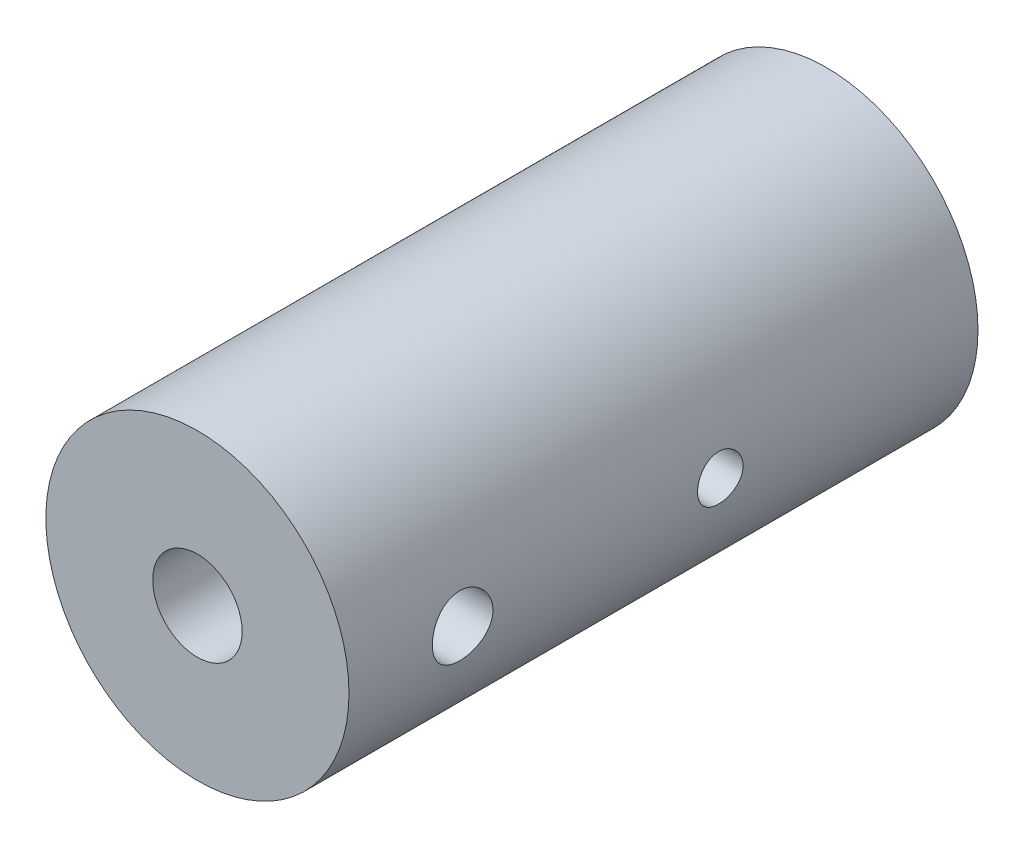
from build123d import *

# Parameters (mm, degrees)
SKETCH1_R           = 10
BOSS_EXTRUDE1_DEPTH = 41.5
SKETCH2_R           = 2.95
CUT_EXTRUDE1_DEPTH  = 15
SKETCH3_R           = 6
CUT_EXTRUDE2_DEPTH  = 22
CUT_EXTRUDE3_REACH  = 49.141
SKETCH4_R           = 1.5
SKETCH4_R_2         = 2
CUT_EXTRUDE4_REACH  = 69.141
CUT_EXTRUDE4_START  = -20
SKETCH4_2_R         = 1.5
SKETCH4_2_R_2       = 2


with BuildPart() as part:
    # Sketch1 → Boss-Extrude1 (new body)
    with BuildSketch(Plane.XY):
        Circle(SKETCH1_R)
    extrude(amount=BOSS_EXTRUDE1_DEPTH)

    # Sketch2 → Cut-Extrude1 (cut)
    with BuildSketch(Plane.XY.offset(41.5)):
        Circle(SKETCH2_R)
    extrude(amount=-CUT_EXTRUDE1_DEPTH, mode=Mode.SUBTRACT)

    # Sketch3 → Cut-Extrude2 (cut)
    with BuildSketch(Plane(origin=(0, 0, 0), x_dir=(-1, 0, 0), z_dir=(0, 0, -1))):
        Circle(SKETCH3_R)
    extrude(amount=-CUT_EXTRUDE2_DEPTH, mode=Mode.SUBTRACT)

    # Sketch4 → Cut-Extrude3 (cut, up to next)
    with BuildSketch(Plane.ZY.offset(10), mode=Mode.PRIVATE) as cut_extrude3_sk1:
        with Locations((17, 0)):
            Circle(SKETCH4_R)
    cut_extrude3_tool1 = extrude(cut_extrude3_sk1.sketch, amount=-CUT_EXTRUDE3_REACH, mode=Mode.PRIVATE) & part.part
    # Sketch4 → Cut-Extrude3 (cut, up to next)
    with BuildSketch(Plane.ZY.offset(10), mode=Mode.PRIVATE) as cut_extrude3_sk2:
        with Locations((34, 0)):
            Circle(SKETCH4_R_2)
    cut_extrude3_tool2 = extrude(cut_extrude3_sk2.sketch, amount=-CUT_EXTRUDE3_REACH, mode=Mode.PRIVATE) & part.part
    add(cut_extrude3_tool1.solids().sort_by_distance((-10, 0, 17))[0], mode=Mode.SUBTRACT)
    add(cut_extrude3_tool2.solids().sort_by_distance((-10, 0, 34))[0], mode=Mode.SUBTRACT)

    # Sketch4_2 → Cut-Extrude4 (cut, up to next)
    with BuildSketch(Plane.ZY.offset(10).offset(CUT_EXTRUDE4_START), mode=Mode.PRIVATE) as cut_extrude4_sk1:
        with Locations((17, 0)):
            Circle(SKETCH4_2_R)
    cut_extrude4_tool1 = extrude(cut_extrude4_sk1.sketch, amount=CUT_EXTRUDE4_REACH, mode=Mode.PRIVATE) & part.part
    # Sketch4_2 → Cut-Extrude4 (cut, up to next)
    with BuildSketch(Plane.ZY.offset(10).offset(CUT_EXTRUDE4_START), mode=Mode.PRIVATE) as cut_extrude4_sk2:
        with Locations((34, 0)):
            Circle(SKETCH4_2_R_2)
    cut_extrude4_tool2 = extrude(cut_extrude4_sk2.sketch, amount=CUT_EXTRUDE4_REACH, mode=Mode.PRIVATE) & part.part
    add(cut_extrude4_tool1.solids().sort_by_distance((10, 0, 17))[0], mode=Mode.SUBTRACT)
    add(cut_extrude4_tool2.solids().sort_by_distance((10, 0, 34))[0], mode=Mode.SUBTRACT)


solid = part.part
